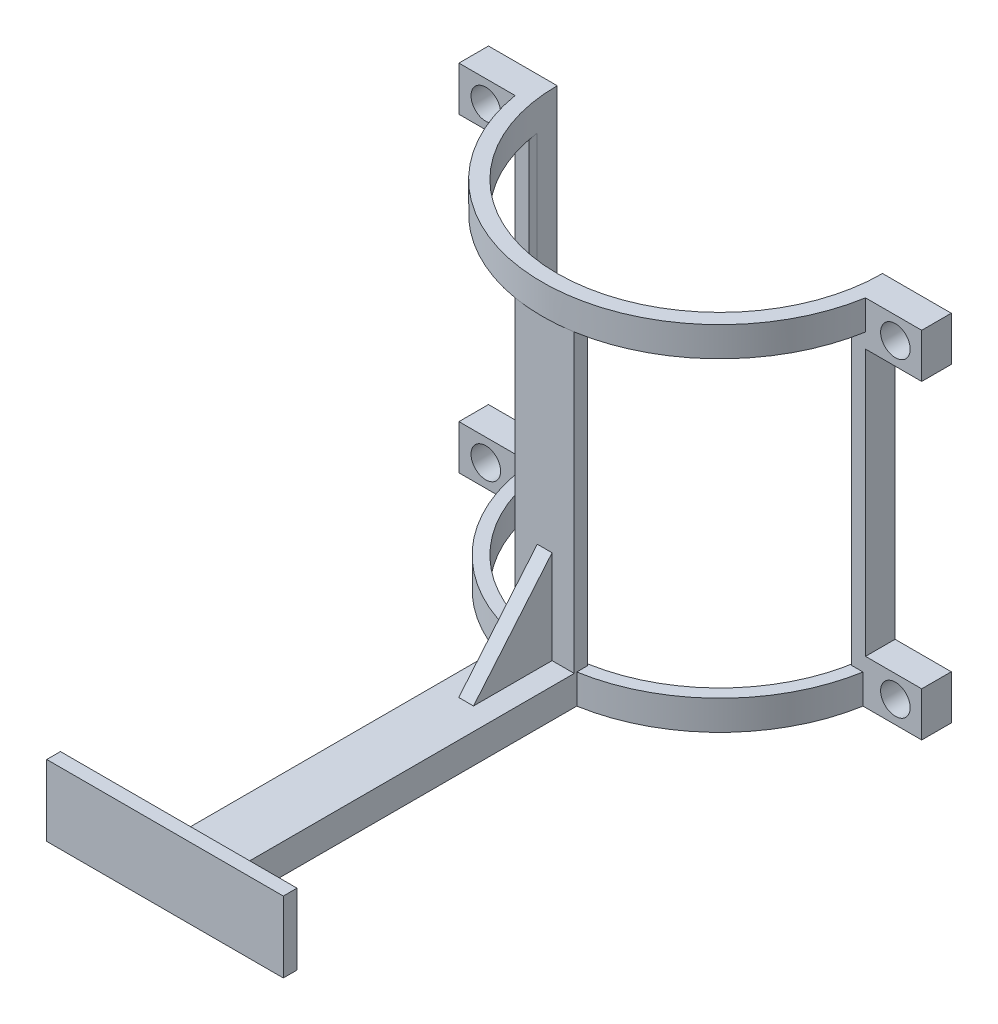
from build123d import *

# Parameters (mm, degrees)
EXTRUDE_1_DEPTH      = 20
EXTRUDE_2_REACH      = 387.225
EXTRUDE_2_END_RADIUS = 118.5
SKETCH_4_W           = 40
SKETCH_4_H           = 9
EXTRUDE_3_DEPTH      = 200
EXTRUDE_5_DEPTH      = 20
RIB_6_REACH          = 455.87
SKETCH_10_WALL_W     = 992.30498819
SKETCH_10_WALL_H     = 10
EXTRUDE_6_DEPTH      = 10
EXTRUDE_7_DEPTH      = 20
SKETCH_13_R          = 10
CUT_EXTRUDE_1_DEPTH  = 20
CUT_EXTRUDE_2_DEPTH  = 240
CUT_EXTRUDE_3_REACH  = 452.258
SKETCH_15_W          = 160
SKETCH_15_H          = 0.725633759


with BuildPart() as part:
    # 草图1 → 凸台-拉伸1 (new body)
    with BuildSketch(Plane(origin=(0, 0, 0), x_dir=(1, 0, 0), z_dir=(0, 1, 0))):
        with BuildLine():
            Line((-118.5, 0), (-108.5, 0))
            ThreePointArc((-108.5, 0), (0, -108.5), (108.5, 0))
            Line((108.5, 0), (118.5, 0))
            ThreePointArc((118.5, 0), (0, -118.5), (-118.5, 0))
        make_face()
    extrude(amount=EXTRUDE_1_DEPTH)

    # 凸台-拉伸2: up to this cylinder (the profile starts outside it)
    extrude_2_end = Plane(origin=(0, 10, 0), z_dir=(0, -1, 0)) * Cylinder(EXTRUDE_2_END_RADIUS, 1012.45, mode=Mode.PRIVATE)
    # 草图3 → 凸台-拉伸2 (add, up to the surface)
    with BuildSketch(Plane.XY.offset(366), mode=Mode.PRIVATE) as extrude_2_sk1:
        Polygon((0, 0), (20, 0), (20, 20), (-20, 20), (-20, 0), align=None)
    extrude_2_tool1 = extrude(extrude_2_sk1.sketch, amount=-EXTRUDE_2_REACH, mode=Mode.PRIVATE) - extrude_2_end
    add(extrude_2_tool1.solids().sort_by_distance((0, 10, 366))[0])

    # 草图4 → 凸台-拉伸3 (add)
    with BuildSketch(Plane(origin=(0, 20, 0), x_dir=(1, 0, 0), z_dir=(0, 1, 0))):
        with Locations((0, -114)):
            Rectangle(SKETCH_4_W, SKETCH_4_H)
    extrude(amount=EXTRUDE_3_DEPTH)

    # 草图5 → 凸台-拉伸5 (add)
    with BuildSketch(Plane(origin=(0, 220, 0), x_dir=(1, 0, 0), z_dir=(0, 1, 0))):
        with BuildLine():
            Line((-120.175912728, 0), (-108.5, 0))
            ThreePointArc((-108.5, 0), (0, -108.5), (108.5, 0))
            Line((108.5, 0), (120.175912728, 0))
            ThreePointArc((120.175912728, 0), (0, -120.175912728), (-120.175912728, 0))
        make_face()
    extrude(amount=EXTRUDE_5_DEPTH)

    # 草图10 wall → 筋6 (add, up to next)
    with BuildSketch(Plane(origin=(0, 51.594277654, 145.071057526), x_dir=(0, -0.765324590967, 0.643644521814), z_dir=(0, -0.643644521814, -0.765324590967)), mode=Mode.PRIVATE) as rib_6_sk1:
        Rectangle(SKETCH_10_WALL_W, SKETCH_10_WALL_H)
    rib_6_tool1 = extrude(rib_6_sk1.sketch, amount=RIB_6_REACH, mode=Mode.PRIVATE) - part.part
    add(rib_6_tool1.solids().sort_by_distance((0, 51.594277654, 145.071057526))[0])

    # 草图11 → 凸台-拉伸6 (add)
    with BuildSketch(Plane.XY.offset(366)):
        Polygon((-80, 48), (80, 48), (80, 38), (80, 20), (80, 0), (-80, 0), (-80, 20), (-80, 38), align=None)
    extrude(amount=EXTRUDE_6_DEPTH)

    # 草图12 → 凸台-拉伸7 (add)
    with BuildSketch(Plane.XY):
        Polygon((-109, 0), (-156.5, 0), (-156.5, 30), (-118.5, 30), (-118.5, 210), (-156.5, 210), (-156.5, 240), (-109, 240), align=None)
        Polygon((156.5, 0), (109, 0), (109, 240), (156.5, 240), (156.5, 210), (118.5, 210), (118.5, 30), (156.5, 30), align=None)
    extrude(amount=EXTRUDE_7_DEPTH)

    # 草图13 → 切除-拉伸1 (cut)
    with BuildSketch(Plane(origin=(0, 0, 0), x_dir=(-1, 0, 0), z_dir=(0, 0, -1))):
        with Locations((138.306064525, 225)):
            Circle(SKETCH_13_R)
        with Locations((138.306064525, 15)):
            Circle(SKETCH_13_R)
        with Locations((-138.70464108, 225)):
            Circle(SKETCH_13_R)
        with Locations((-138.70464108, 15)):
            Circle(SKETCH_13_R)
    extrude(amount=-CUT_EXTRUDE_1_DEPTH, mode=Mode.SUBTRACT)

    # 草图14 → 切除-拉伸2 (cut)
    with BuildSketch(Plane(origin=(0, 0, 0), x_dir=(1, 0, 0), z_dir=(0, 1, 0))):
        with BuildLine():
            Line((-110, 0), (110, 0))
            ThreePointArc((110, 0), (0, -110), (-110, 0))
        make_face()
    extrude(amount=CUT_EXTRUDE_2_DEPTH, mode=Mode.SUBTRACT)

    # 草图15 → 切除-拉伸3 (cut, up to next)
    with BuildSketch(Plane(origin=(0, 48, 0), x_dir=(1, 0, 0), z_dir=(0, 1, 0)), mode=Mode.PRIVATE) as cut_extrude_3_sk1:
        with Locations((0, -375.637183121)):
            Rectangle(SKETCH_15_W, SKETCH_15_H)
    cut_extrude_3_tool1 = extrude(cut_extrude_3_sk1.sketch, amount=-CUT_EXTRUDE_3_REACH, mode=Mode.PRIVATE) & part.part
    add(cut_extrude_3_tool1.solids().sort_by_distance((0, 48, 375.637183))[0], mode=Mode.SUBTRACT)


solid = part.part
